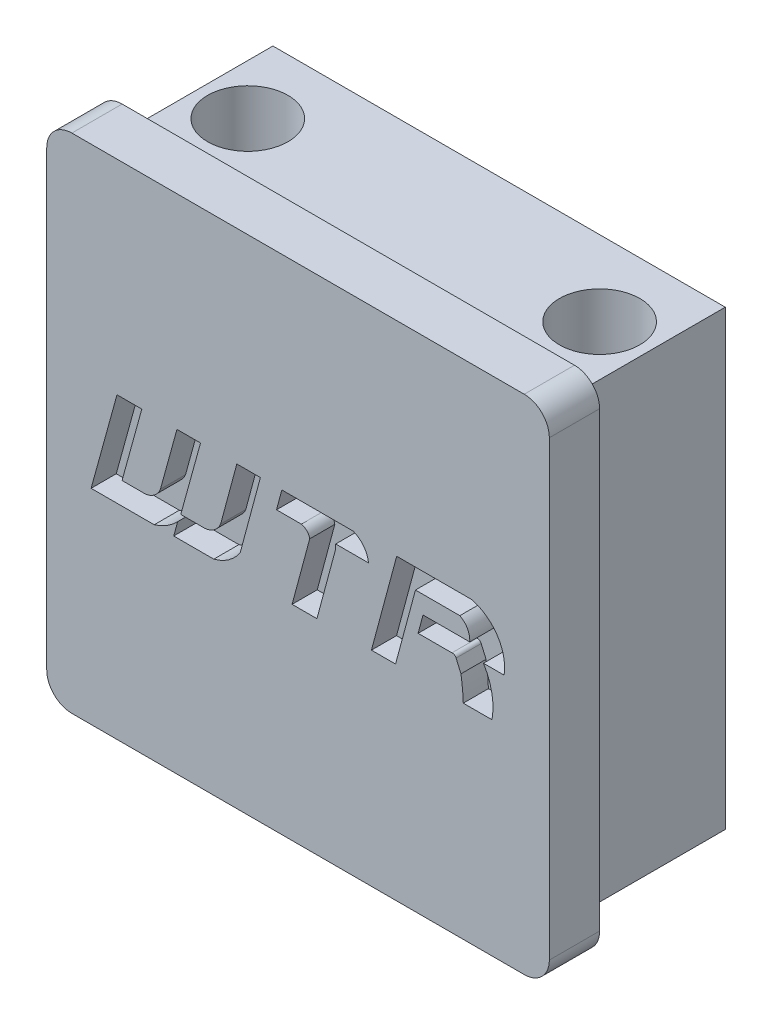
from build123d import *

# Parameters (mm, degrees)
SKETCH_1_W          = 18
SKETCH_1_H          = 18
EXTRUDE_1_DEPTH     = 6
SKETCH_2_R          = 1.6
CUT_EXTRUDE_1_DEPTH = 19
SKETCH_3_W          = 20
SKETCH_3_H          = 20
EXTRUDE_2_DEPTH     = 2
FILLET_1_R          = 1
CUT_EXTRUDE_2_DEPTH = 1


with BuildPart() as part:
    # 草图1 → 凸台-拉伸1 (new body)
    with BuildSketch(Plane.XY):
        Rectangle(SKETCH_1_W, SKETCH_1_H)
    extrude(amount=EXTRUDE_1_DEPTH)

    # 草图2 → 切除-拉伸1 (cut, through all)
    with BuildSketch(Plane(origin=(0, 9, 0), x_dir=(1, 0, 0), z_dir=(0, 1, 0))):
        with Locations((-7, -3)):
            Circle(SKETCH_2_R)
        with Locations((7, -3)):
            Circle(SKETCH_2_R)
    extrude(amount=-CUT_EXTRUDE_1_DEPTH, mode=Mode.SUBTRACT)

    # 草图3 → 凸台-拉伸2 (add)
    with BuildSketch(Plane.XY.offset(6)):
        Rectangle(SKETCH_3_W, SKETCH_3_H)
    extrude(amount=EXTRUDE_2_DEPTH)

    # 圆角1
    fillet_1_edges = [part.edges().sort_by_distance(p)[0] for p in [
        (10, -10, 7),
        (10, 10, 7),
        (-10, 10, 7),
        (-10, -10, 7),
    ]]
    fillet(fillet_1_edges, radius=FILLET_1_R)

    # 草图5 → 切除-拉伸2 (cut)
    with BuildSketch(Plane.XY.offset(8)):
        with BuildLine():
            Line((-7.204561004, 1.879394949), (-8.234522443, -1.859506165))
            Line((-8.234522443, -1.859506165), (-5.723109619, -1.859506165))
            ThreePointArc((-5.723109619, -1.859506165), (-5.218538697, -1.632457047), (-4.78861912, -1.284157931))
            Line((-4.78861912, -1.284157931), (-4.947111275, -1.859506165))
            Line((-4.947111275, -1.859506165), (-3.352787404, -1.859506165))
            ThreePointArc((-3.352787404, -1.859506165), (-2.759972983, -1.585355224), (-2.30360072, -1.118116491))
            Line((-2.30360072, -1.118116491), (-1.497804292, 1.879394949))
            Line((-1.497804292, 1.879394949), (-2.436323584, 1.879394949))
            Line((-2.436323584, 1.879394949), (-3.079504637, -0.513197642))
            ThreePointArc((-3.079504637, -0.513197642), (-3.32542599, -0.827982147), (-3.696433402, -0.976036515))
            Line((-3.696433402, -0.976036515), (-4.666789972, -0.976036515))
            Line((-4.666789972, -0.976036515), (-3.880199418, 1.879394949))
            Line((-3.880199418, 1.879394949), (-4.81871871, 1.879394949))
            Line((-4.81871871, 1.879394949), (-5.477810253, -0.513197642))
            ThreePointArc((-5.477810253, -0.513197642), (-5.7047457, -0.820725721), (-6.053961641, -0.976036515))
            Line((-6.053961641, -0.976036515), (-7.003517302, -0.976036515))
            Line((-7.003517302, -0.976036515), (-6.216926747, 1.879394949))
            Line((-6.216926747, 1.879394949), (-7.204561004, 1.879394949))
        make_face()
        with BuildLine():
            Line((-0.857127264, 1.088853082), (-0.644612375, 1.879394949))
            Line((-0.644612375, 1.879394949), (2.196209614, 1.879394949))
            ThreePointArc((2.196209614, 1.879394949), (2.612575491, 1.570775142), (2.803252851, 1.088853082))
            Line((2.803252851, 1.088853082), (1.498562909, 1.088853082))
            Line((1.498562909, 1.088853082), (1.498562909, 0.920146657))
            Line((1.498562909, 0.920146657), (0.751331627, -1.859506165))
            Line((0.751331627, -1.859506165), (-0.236975463, -1.859506165))
            Line((-0.236975463, -1.859506165), (0.463990432, 0.748042361))
            ThreePointArc((0.463990432, 0.748042361), (0.35056842, 0.970657535), (0.130450539, 1.088853082))
            Line((0.130450539, 1.088853082), (-0.857127264, 1.088853082))
        make_face()
        with BuildLine():
            Line((3.92496477, 1.879394949), (2.919866632, -1.859506165))
            Line((2.919866632, -1.859506165), (3.879786702, -1.859506165))
            Line((3.879786702, -1.859506165), (4.67236995, 1.088853082))
            Line((4.67236995, 1.088853082), (6.439189541, 1.088853082))
            ThreePointArc((6.439189541, 1.088853082), (6.74191311, 0.79302609), (6.831437365, 0.379334689))
            Line((6.831437365, 0.379334689), (4.973337874, 0.379334689))
            Line((4.973337874, 0.379334689), (4.777076341, -0.350745725))
            Line((4.777076341, -0.350745725), (6.123295998, -0.350745725))
            ThreePointArc((6.123295998, -0.350745725), (6.221884558, -0.372626448), (6.288711068, -0.448340962))
            Line((6.288711068, -0.448340962), (6.481965147, -0.894824524))
            ThreePointArc((6.481965147, -0.894824524), (6.543334906, -1.375731382), (6.574951556, -1.859506165))
            Line((6.574951556, -1.859506165), (7.717356009, -1.859506165))
            ThreePointArc((7.717356009, -1.859506165), (7.71253802, -0.938991532), (7.378394237, -0.081251283))
            Line((7.378394237, -0.081251283), (8.199786702, -0.081251283))
            ThreePointArc((8.199786702, -0.081251283), (7.934816182, 1.144935193), (6.917805112, 1.879394949))
            Line((6.917805112, 1.879394949), (3.92496477, 1.879394949))
        make_face()
    extrude(amount=-CUT_EXTRUDE_2_DEPTH, mode=Mode.SUBTRACT)


solid = part.part
